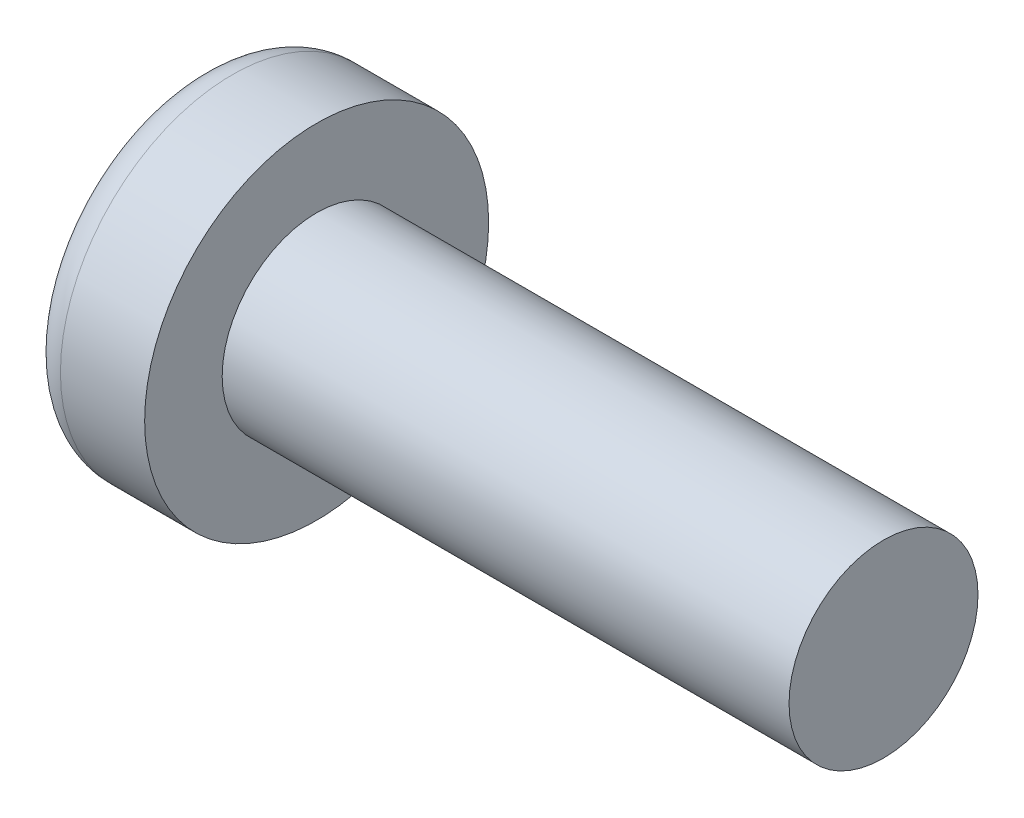
from build123d import *

# Parameters (mm, degrees)
SKETCH3_W         = 0.74
SKETCH3_H         = 2.9
SKETCH4_W         = 0.37
SKETCH4_H         = 0.37
CIRPATTERN1_COUNT = 2
CIRPATTERN1_ANGLE = 90


with BuildPart() as part:
    # BodySke → Base-Revolve (revolve)
    with BuildSketch(Plane.XY):
        with BuildLine():
            Line((1.45, 0.975), (1.45, 1.775))
            Line((1.45, 1.775), (0.581021046, 1.775))
            ThreePointArc((0.581021046, 1.775), (0.368797595, 1.705794097), (0.23816923, 1.524784483))
            ThreePointArc((0.23816923, 1.524784483), (0.059901122, 0.771636621), (0, 0))
            Line((0, 0), (7.3, 0))
            Line((7.3, 0), (7.3, 0.975))
            Line((7.3, 0.975), (1.45, 0.975))
        make_face()
    revolve(axis=Axis((-25.4, 0, 0), (1, 0, 0)))

    # Sketch3 → Cut-Loft1 section 0
    with BuildSketch(Plane(origin=(0, 0, 0), x_dir=(0, 0, -1), z_dir=(1, 0, 0))):
        Rectangle(SKETCH3_W, SKETCH3_H)
    # Sketch4 → Cut-Loft1 section 1
    with BuildSketch(Plane(origin=(1.76, 0, 0), x_dir=(0, 0, -1), z_dir=(1, 0, 0))):
        Rectangle(SKETCH4_W, SKETCH4_H)
    cut_loft1 = loft(mode=Mode.SUBTRACT)

    # CirPattern1: Cut-Loft1 ×2 about axis
    cirpattern1_axis = Axis((0, 0, 0), (1, 0, 0))
    for i in range(1, CIRPATTERN1_COUNT):
        add(cut_loft1.rotate(cirpattern1_axis, i * CIRPATTERN1_ANGLE / (CIRPATTERN1_COUNT - 1)), mode=Mode.SUBTRACT)


solid = part.part
